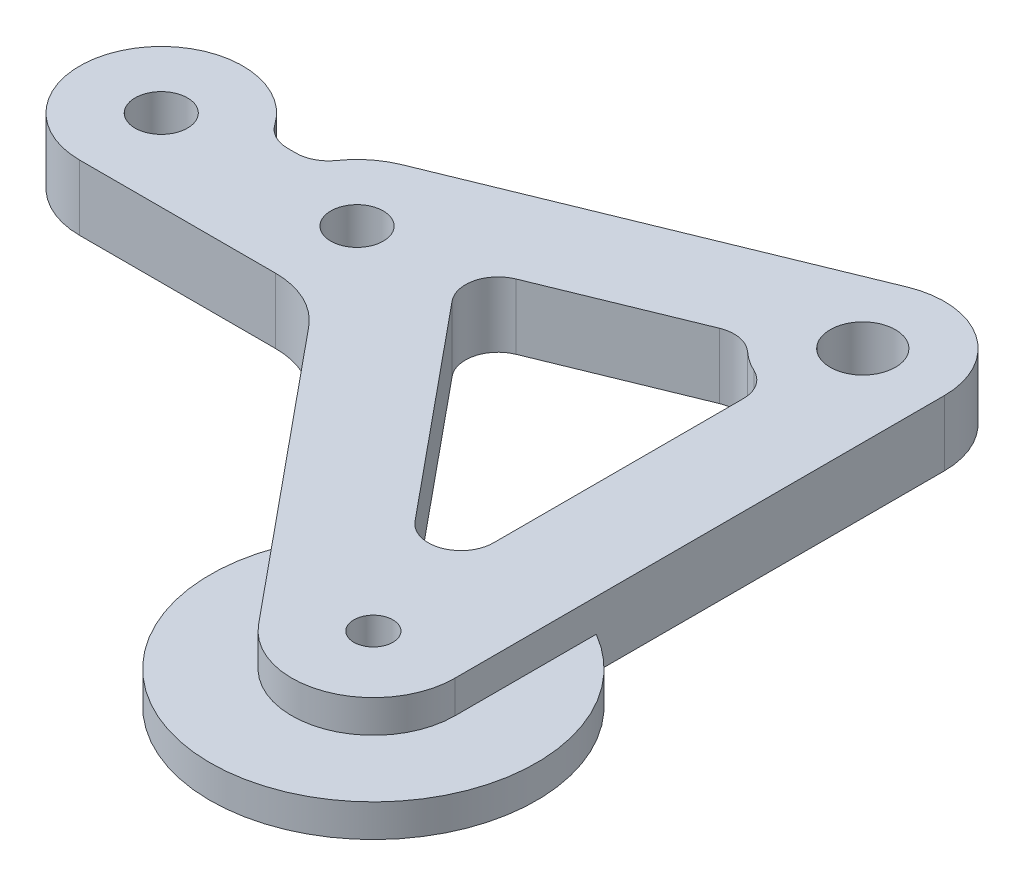
from build123d import *

# Parameters (mm, degrees)
BOSS_EXTRUDE1_DEPTH         = 6.35
FILLET3_R                   = 3.175
F_10_CLEARANCE_HOLE1_D      = 5.1054
F_1_4_0_25_DIAMETER_HOLE1_D = 6.35
FILLET2_R                   = 3.175
F_10_24_TAPPED_HOLE1_D      = 3.7973
BOSS_EXTRUDE2_START         = -3.175
BOSS_EXTRUDE2_DEPTH         = 3.175
CUT_EXTRUDE1_DEPTH          = 7.35


with BuildPart() as part:
    # Sketch1 → Boss-Extrude1 (new body)
    with BuildSketch(Plane(origin=(0, 0, 0), x_dir=(1, 0, 0), z_dir=(0, 1, 0))):
        with BuildLine():
            Line((0, -7.9375), (19.05, -7.9375))
            ThreePointArc((19.05, -7.9375), (22.439261793, -8.697478788), (25.179511411, -10.831886268))
            Line((25.179511411, -10.831886268), (47.845488589, -38.380613732))
            ThreePointArc((47.845488589, -38.380613732), (56.653703924, -40.809343918), (61.9125, -33.3375))
            Line((61.9125, -33.3375), (61.9125, 14.2875))
            ThreePointArc((61.9125, 14.2875), (58.399282876, 20.877615878), (50.969601787, 21.634028965))
            Line((50.969601787, 21.634028965), (16.044601787, 7.346528965))
            ThreePointArc((16.044601787, 7.346528965), (13.502817622, 5.677382664), (11.775161084, 3.175))
            Line((11.775161084, 3.175), (7.274838916, 3.175))
            ThreePointArc((7.274838916, 3.175), (6.75922379, 4.161345937), (6.110713691, 5.065874499))
            Line((6.110713691, 5.065874499), (-18.894457111, 35.228374499))
            ThreePointArc((-18.894457111, 35.228374499), (-23.603599947, 37.97527834), (-28.973920802, 37.036576643))
            Line((-28.973920802, 37.036576643), (-67.46875, 14.811576643))
            ThreePointArc((-67.46875, 14.811576643), (-71.279874161, 6.363503718), (-64.484525706, 0.061294354))
            Line((-64.484525706, 0.061294354), (-0.984525706, -7.876205646))
            ThreePointArc((-0.984525706, -7.876205646), (-0.493215942, -7.922161592), (0, -7.9375))
        make_face()
        with BuildLine():
            Line((27.252413672, 1.640330855), (52.3875, -28.909406206))
            Line((52.3875, -28.909406206), (52.3875, 6.510370067))
            ThreePointArc((52.3875, 6.510370067), (49.550717124, 7.697384122), (47.377980705, 9.873517369))
            Line((47.377980705, 9.873517369), (27.252413672, 1.640330855))
        make_face(mode=Mode.SUBTRACT)
        with BuildLine():
            Line((-49.23043706, 7.753658904), (-11.734122555, 3.066619591))
            ThreePointArc((-11.734122555, 3.066619591), (-8.556248755, 4.690794106), (-8.896026797, 8.243451649))
            Line((-8.896026797, 8.243451649), (-21.263790491, 23.162072897))
            ThreePointArc((-21.263790491, 23.162072897), (-26.406741657, 22.34972166), (-30.946612893, 24.899119705))
            Line((-30.946612893, 24.899119705), (-50.424126778, 13.65377182))
            ThreePointArc((-50.424126778, 13.65377182), (-51.948576442, 10.27454265), (-49.23043706, 7.753658904))
        make_face(mode=Mode.SUBTRACT)
    extrude(amount=BOSS_EXTRUDE1_DEPTH)

    # Fillet3
    fillet3_edges = [part.edges().sort_by_distance(p)[0] for p in [
        (47.377980705, 3.175, -9.873517369),
        (27.252413672, 3.175, -1.640330855),
        (52.3875, 3.175, 28.909406206),
        (52.3875, 3.175, -6.510370067),
        (-21.263790491, 3.175, -23.162072897),
        (-30.946612893, 3.175, -24.899119705),
    ]]
    fillet(fillet3_edges, radius=FILLET3_R)

    # #10 Clearance Hole1 (through all)
    with Locations(Plane(origin=(0, 6.35, 0), x_dir=(1, 0, 0), z_dir=(0, 1, 0))):
        with Locations((0, 0), (19.05, 0)):
            Hole(F_10_CLEARANCE_HOLE1_D / 2)

    # 1/4 (0.25) Diameter Hole1 (through all)
    with Locations(Plane(origin=(0, 6.35, 0), x_dir=(1, 0, 0), z_dir=(0, 1, 0))):
        with Locations((53.975, 14.2875), (-63.5, 7.9375)):
            Hole(F_1_4_0_25_DIAMETER_HOLE1_D / 2)

    # Fillet2
    fillet2_edges = [part.edges().sort_by_distance(p)[0] for p in [
        (7.274838916, 3.175, -3.175),
        (11.775161084, 3.175, -3.175),
    ]]
    fillet(fillet2_edges, radius=FILLET2_R)

    # #10-24 Tapped Hole1 (through all)
    with Locations(Plane(origin=(0, 6.35, 0), x_dir=(1, 0, 0), z_dir=(0, 1, 0))):
        with Locations((53.975, -33.3375), (-25.005170802, 30.1625)):
            Hole(F_10_24_TAPPED_HOLE1_D / 2)

    # Sketch8 → Boss-Extrude2 (add)
    with BuildSketch(Plane(origin=(0, 6.35, 0), x_dir=(1, 0, 0), z_dir=(0, 1, 0)).offset(BOSS_EXTRUDE2_START)):
        with BuildLine():
            Line((39.110559377, -27.763988542), (47.845488589, -38.380613732))
            ThreePointArc((47.845488589, -38.380613732), (56.653703924, -40.809343918), (61.9125, -33.3375))
            Line((61.9125, -33.3375), (61.9125, -19.589346715))
            ThreePointArc((61.9125, -19.589346715), (59.332407848, -48.281187836), (39.110559377, -27.763988542))
        make_face()
        with BuildLine():
            Line((-28.973920802, 37.036576643), (-40.880170802, 30.1625))
            ThreePointArc((-40.880170802, 30.1625), (-22.202029092, 45.78805668), (-10.120105094, 24.644307915))
            Line((-10.120105094, 24.644307915), (-18.894457111, 35.228374499))
            ThreePointArc((-18.894457111, 35.228374499), (-23.603599947, 37.97527834), (-28.973920802, 37.036576643))
        make_face()
    extrude(amount=-BOSS_EXTRUDE2_DEPTH)

    # Sketch9 → Cut-Extrude1 (cut, through all)
    with BuildSketch(Plane(origin=(0, 6.35, 0), x_dir=(1, 0, 0), z_dir=(0, 1, 0))):
        with BuildLine():
            Line((6.110713691, 5.065874499), (-10.120105094, 24.644307915))
            ThreePointArc((-10.120105094, 24.644307915), (-22.202029092, 45.78805668), (-40.880170802, 30.1625))
            Line((-40.880170802, 30.1625), (-67.46875, 14.811576643))
            ThreePointArc((-67.46875, 14.811576643), (-71.279874161, 6.363503718), (-64.484525706, 0.061294354))
            Line((-64.484525706, 0.061294354), (-0.984525706, -7.876205646))
            ThreePointArc((-0.984525706, -7.876205646), (-6.960158794, 3.815769361), (6.110713691, 5.065874499))
        make_face()
    extrude(amount=-CUT_EXTRUDE1_DEPTH, mode=Mode.SUBTRACT)


solid = part.part
